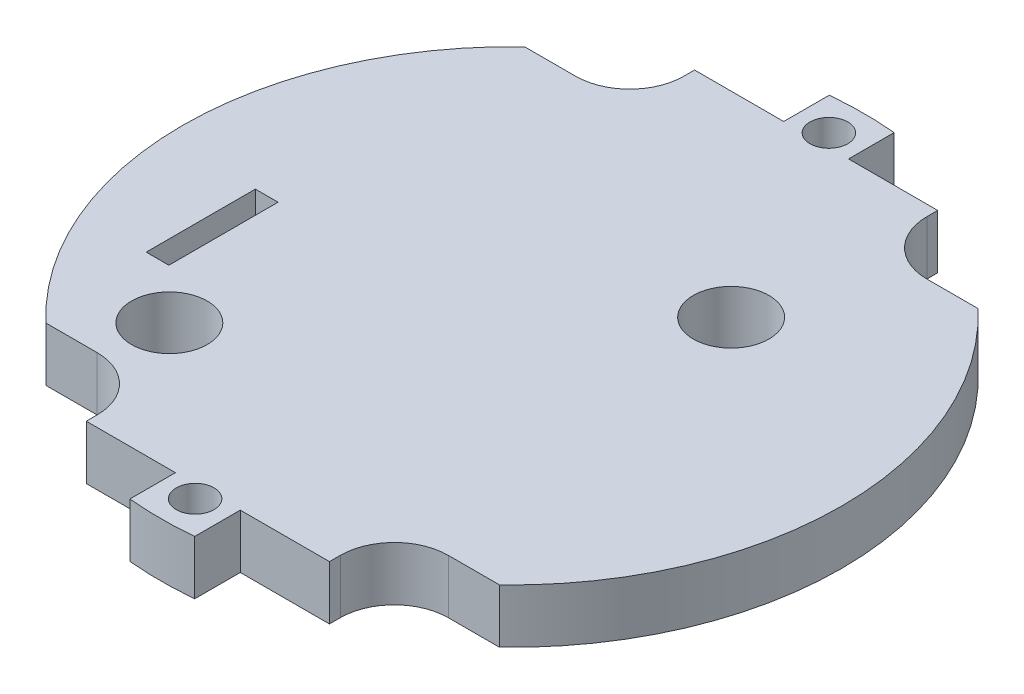
from build123d import *

# Parameters (mm, degrees)
SKETCH2_R           = 1.75
BOSS_EXTRUDE1_DEPTH = 5
FILLET1_R           = 5
SKETCH3_R           = 3.5
SKETCH3_W           = 2.1
SKETCH3_H           = 10.1
CUT_EXTRUDE1_DEPTH  = 6


with BuildPart() as part:
    # Sketch2 → Boss-Extrude1 (new body)
    with BuildSketch(Plane(origin=(0, 0, 0), x_dir=(1, 0, 0), z_dir=(0, 1, 0))):
        with BuildLine():
            Line((3, 28.141242251), (3, 32.361242251))
            ThreePointArc((3, 32.361242251), (0, 32.5), (-3, 32.361242251))
            Line((-3, 32.361242251), (-3, 28.141242251))
            Line((-3, 28.141242251), (-11.25, 28.141242251))
            Line((-11.25, 28.141242251), (-11.25, 22.141242251))
            Line((-11.25, 22.141242251), (-20.976543843, 22.141242251))
            ThreePointArc((-20.976543843, 22.141242251), (-30.5, 0), (-20.976543843, -22.141242251))
            Line((-20.976543843, -22.141242251), (-11.25, -22.141242251))
            Line((-11.25, -22.141242251), (-11.25, -28.141242251))
            Line((-11.25, -28.141242251), (-3, -28.141242251))
            Line((-3, -28.141242251), (-3, -32.361242251))
            ThreePointArc((-3, -32.361242251), (0, -32.5), (3, -32.361242251))
            Line((3, -32.361242251), (3, -28.141242251))
            Line((3, -28.141242251), (11.25, -28.141242251))
            Line((11.25, -28.141242251), (11.25, -22.141242251))
            Line((11.25, -22.141242251), (20.976543843, -22.141242251))
            ThreePointArc((20.976543843, -22.141242251), (30.5, 0), (20.976543843, 22.141242251))
            Line((20.976543843, 22.141242251), (11.25, 22.141242251))
            Line((11.25, 22.141242251), (11.25, 28.141242251))
            Line((11.25, 28.141242251), (3, 28.141242251))
        make_face()
        with Locations((0, 29.32)):
            Circle(SKETCH2_R, mode=Mode.SUBTRACT)
        with Locations((0, -29.32)):
            Circle(SKETCH2_R, mode=Mode.SUBTRACT)
    extrude(amount=BOSS_EXTRUDE1_DEPTH)

    # Fillet1
    fillet1_edges = [part.edges().sort_by_distance(p)[0] for p in [
        (-11.25, 2.5, -22.141242251),
        (11.25, 2.5, -22.141242251),
        (11.25, 2.5, 22.141242251),
        (-11.25, 2.5, 22.141242251),
    ]]
    fillet(fillet1_edges, radius=FILLET1_R)

    # Sketch3 → Cut-Extrude1 (cut, through all)
    with BuildSketch(Plane(origin=(0, 5, 0), x_dir=(1, 0, 0), z_dir=(0, 1, 0))):
        with Locations((10.253456157, 10.021242251)):
            Circle(SKETCH3_R)
        with Locations((-15.293456157, -16.411242251)):
            Circle(SKETCH3_R)
        with Locations((-20.976543843, -6.771242251)):
            Rectangle(SKETCH3_W, SKETCH3_H)
    extrude(amount=-CUT_EXTRUDE1_DEPTH, mode=Mode.SUBTRACT)


solid = part.part
